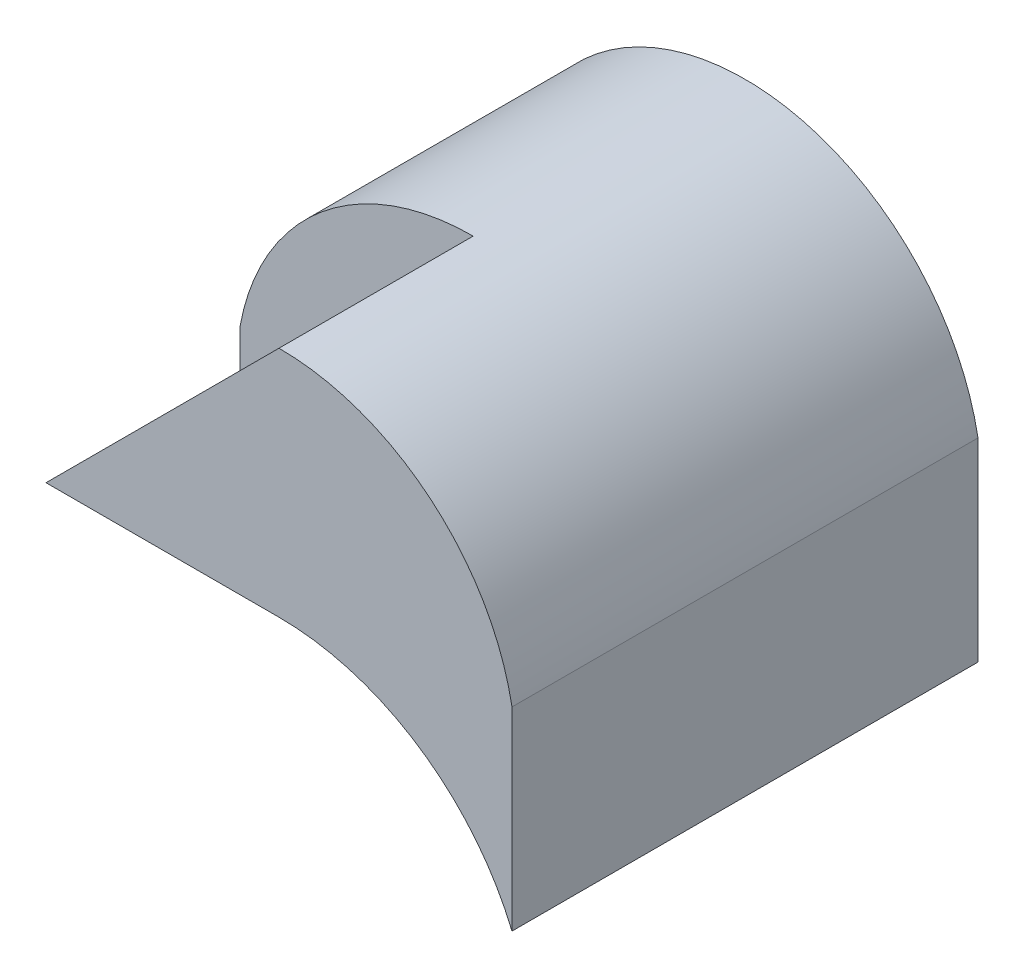
from build123d import *

# Parameters (mm, degrees)
SKETCH1_W           = 6
SKETCH1_H           = 6
BOSS_EXTRUDE1_DEPTH = 5
CUT_EXTRUDE4_DEPTH  = 12.5
CUT_EXTRUDE5_DEPTH  = 2.5


with BuildPart() as part:
    # Sketch1 → Boss-Extrude1 (new body)
    with BuildSketch(Plane(origin=(0, 0, 0), x_dir=(1, 0, 0), z_dir=(0, 1, 0))):
        Rectangle(SKETCH1_W, SKETCH1_H)
    extrude(amount=BOSS_EXTRUDE1_DEPTH)

    # Sketch5 → Cut-Extrude4 (cut)
    with BuildSketch(Plane.XY.offset(3)):
        with BuildLine():
            Line((-3, 5), (-3, 2.5))
            ThreePointArc((-3, 2.5), (-1.952562419, 4.293074903), (0, 5))
            Line((0, 5), (-3, 5))
        make_face()
        with BuildLine():
            ThreePointArc((0, 5), (1.952562419, 4.293074903), (3, 2.5))
            Line((3, 2.5), (3, 5))
            Line((3, 5), (0, 5))
        make_face()
        with BuildLine():
            ThreePointArc((-3, 0), (0, 2), (3, 0))
            Line((3, 0), (-3, 0))
        make_face()
    extrude(amount=-CUT_EXTRUDE4_DEPTH, mode=Mode.SUBTRACT)

    # Sketch6 → Cut-Extrude5 (cut)
    with BuildSketch(Plane.XY.offset(3)):
        with BuildLine():
            Line((-3, 2.5), (-3, 2))
            Line((-3, 2), (0, 5))
            ThreePointArc((0, 5), (-1.952562419, 4.293074903), (-3, 2.5))
        make_face()
        with BuildLine():
            Line((0, 2), (-3, 2))
            Line((-3, 2), (-3, 0))
            ThreePointArc((-3, 0), (-1.802775638, 1.454163457), (0, 2))
        make_face()
    extrude(amount=-CUT_EXTRUDE5_DEPTH, mode=Mode.SUBTRACT)


solid = part.part
